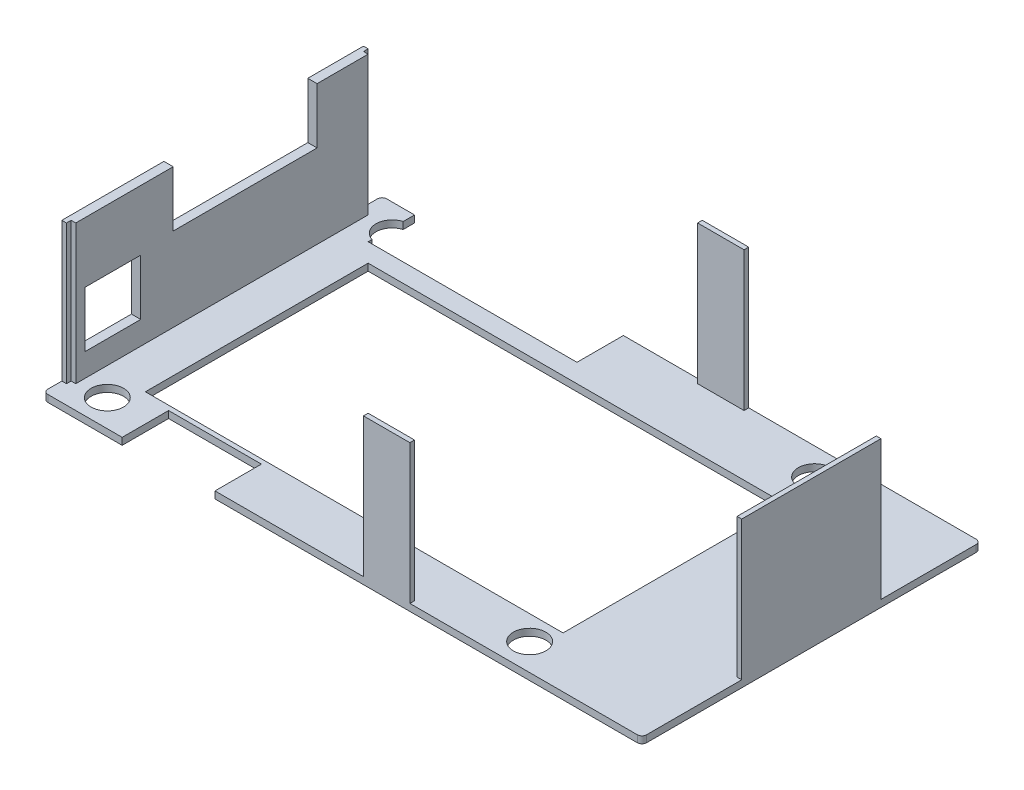
from build123d import *

# Parameters (mm, degrees)
EXTRUDE_1_DEPTH     = 30
SKETCH_1_5_W        = 129
SKETCH_1_5_H        = 73
EXTRUDE_3_DEPTH     = 1.5
SKETCH_4_W          = 1
SKETCH_4_H          = 30
SKETCH_4_W_2        = 10
SKETCH_4_H_2        = 1
EXTRUDE_4_DEPTH     = 30
SKETCH_8_W          = 31
SKETCH_8_H          = 12
SKETCH_8_W_2        = 12
CUT_EXTRUDE_5_DEPTH = 2
SKETCH_6_W          = 90
SKETCH_6_H          = 48
SKETCH_6_W_2        = 20
SKETCH_6_H_2        = 10
SKETCH_6_W_3        = 45
CUT_EXTRUDE_6_DEPTH = 2
FILLET_1_R          = 1
FILLET_6_R          = 1
FILLET_7_R          = 1
SKETCH_10_R         = 3.5
CUT_EXTRUDE_7_DEPTH = 2


with BuildPart() as part:
    # 草图1 → 凸台-拉伸1 (new body)
    with BuildSketch(Plane(origin=(0, 0, 0), x_dir=(1, 0, 0), z_dir=(0, 1, 0))):
        Polygon((-63.5, 32.5), (-64.5, 32.5), (-64.5, -32.5), (-63.5, -32.5), (-63.5, -31.5), (-62.5, -31.5), (-62.5, 31.5), (-63.5, 31.5), align=None)
    extrude(amount=EXTRUDE_1_DEPTH)

    # 草图1<5> → 凸台-拉伸3 (add)
    with BuildSketch(Plane(origin=(0, 0, 0), x_dir=(1, 0, 0), z_dir=(0, 1, 0))):
        Rectangle(SKETCH_1_5_W, SKETCH_1_5_H)
    extrude(amount=-EXTRUDE_3_DEPTH)

    # 草图4 → 凸台-拉伸4 (add)
    with BuildSketch(Plane(origin=(0, 0, 0), x_dir=(1, 0, 0), z_dir=(0, 1, 0))):
        with Locations((64, 0)):
            Rectangle(SKETCH_4_W, SKETCH_4_H)
        with Locations((9.5, -36)):
            Rectangle(SKETCH_4_W_2, SKETCH_4_H_2)
        with Locations((9.5, 36)):
            Rectangle(SKETCH_4_W_2, SKETCH_4_H_2)
    extrude(amount=EXTRUDE_4_DEPTH)

    # 草图8 → 切除-拉伸5 (cut)
    with BuildSketch(Plane.ZY.offset(64.5)):
        with Locations((-5, 24)):
            Rectangle(SKETCH_8_W, SKETCH_8_H)
        with Locations((23.5, 11)):
            Rectangle(SKETCH_8_W_2, SKETCH_8_H)
    extrude(amount=-CUT_EXTRUDE_5_DEPTH, mode=Mode.SUBTRACT)

    # 草图6 → 切除-拉伸6 (cut)
    with BuildSketch(Plane.XZ.offset(1.5)):
        with Locations((-8.5, 1.5)):
            Rectangle(SKETCH_6_W, SKETCH_6_H)
        with Locations((-37.5, 31.5)):
            Rectangle(SKETCH_6_W_2, SKETCH_6_H_2)
        with Locations((-35, -31.5)):
            Rectangle(SKETCH_6_W_3, SKETCH_6_H_2)
    extrude(amount=-CUT_EXTRUDE_6_DEPTH, mode=Mode.SUBTRACT)

    # 圆角1
    fillet_1_edges = [part.edges().sort_by_distance(p)[0] for p in [
        (-64.5, -0.75, -36.5),
    ]]
    fillet(fillet_1_edges, radius=FILLET_1_R)

    # 圆角6
    fillet_6_edges = [part.edges().sort_by_distance(p)[0] for p in [
        (-64.5, -0.75, 36.5),
    ]]
    fillet(fillet_6_edges, radius=FILLET_6_R)

    # 圆角7
    fillet_7_edges = [part.edges().sort_by_distance(p)[0] for p in [
        (64.5, -0.75, -36.5),
        (64.5, -0.75, 36.5),
    ]]
    fillet(fillet_7_edges, radius=FILLET_7_R)

    # 草图10 → 切除-拉伸7 (cut)
    with BuildSketch(Plane(origin=(0, -1.5, 0), x_dir=(-1, 0, 0), z_dir=(0, -1, 0))):
        with Locations((-34.5, 30.7)):
            Circle(SKETCH_10_R)
        with Locations((-34.5, -30.7)):
            Circle(SKETCH_10_R)
        with Locations((56.5, -30.7)):
            Circle(SKETCH_10_R)
        with BuildLine():
            Line((57.5, 27.345898034), (57.5, 34.054101966))
            ThreePointArc((57.5, 34.054101966), (60, 30.7), (57.5, 27.345898034))
        make_face()
    extrude(amount=-CUT_EXTRUDE_7_DEPTH, mode=Mode.SUBTRACT)


solid = part.part
